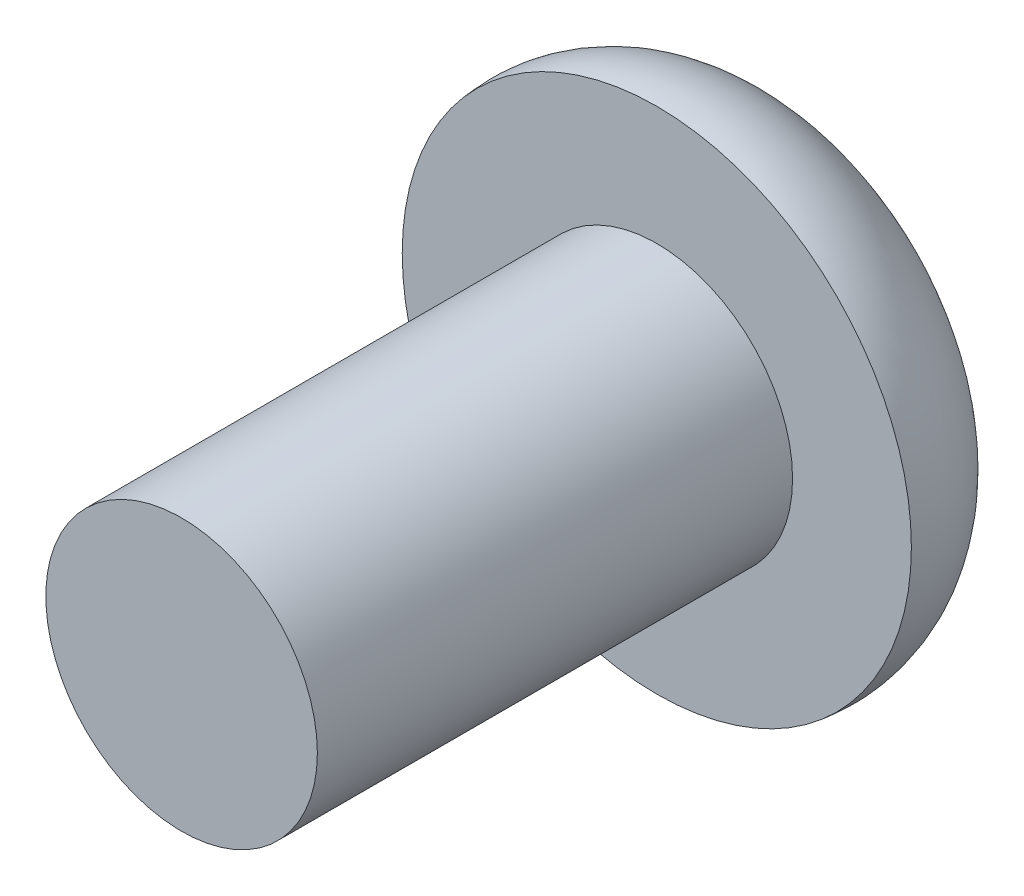
from build123d import *

# Parameters (mm, degrees)
CUT_EXTRUDE1_DEPTH = 1.8


with BuildPart() as part:
    # Sketch1 → Revolve1 (revolve)
    with BuildSketch(Plane(origin=(0, 0, 0), x_dir=(1, 0, 0), z_dir=(0, 1, 0))):
        with BuildLine():
            Line((0, 0), (-2, 0))
            Line((-2, 0), (-2, 7))
            Line((-2, 7), (-3.75, 7))
            ThreePointArc((-3.75, 7), (-3.328768227, 8.397047198), (-2, 9))
            Line((-2, 9), (0, 9))
            Line((0, 9), (0, 0))
        make_face()
    revolve(axis=Axis((0, 0, 0), (0, 0, -1)))

    # Sketch2 → Cut-Extrude1 (cut)
    with BuildSketch(Plane(origin=(0, 0, -9), x_dir=(-1, 0, 0), z_dir=(0, 0, -1))):
        Polygon((0, -1.443375673), (1.25, -0.721687836), (1.25, 0.721687836), (0, 1.443375673), (-1.25, 0.721687836), (-1.25, -0.721687836), align=None)
    extrude(amount=-CUT_EXTRUDE1_DEPTH, mode=Mode.SUBTRACT)


solid = part.part
